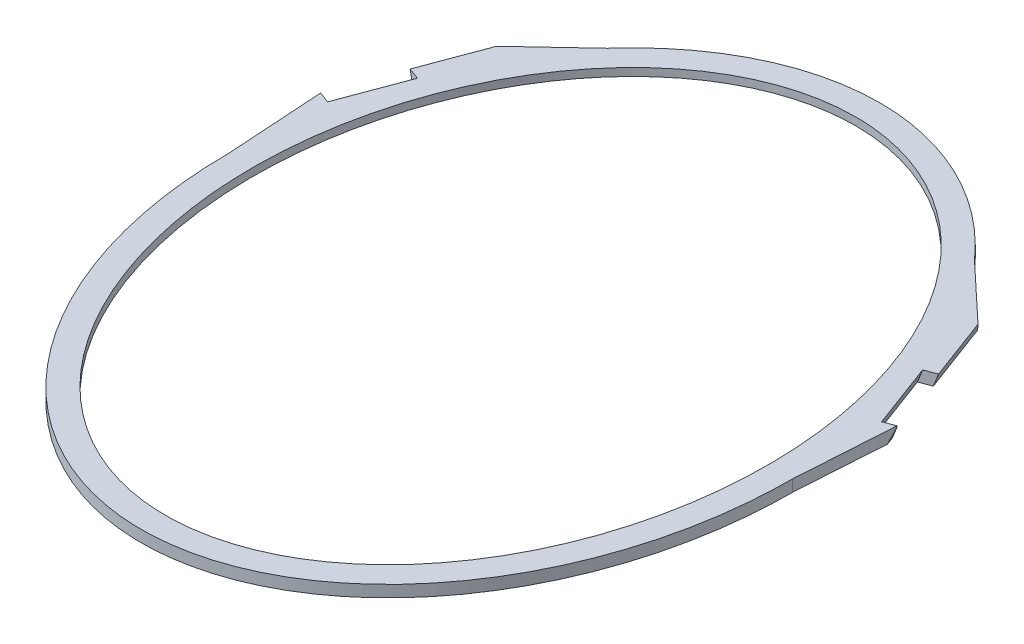
from build123d import *

# Parameters (mm, degrees)
SKETCH1_RX          = 380
SKETCH1_RY          = 290
SKETCH1_RX_2        = 355
SKETCH1_RY_2        = 265
BOSS_EXTRUDE1_DEPTH = 12
SKETCH2_RX          = 365
SKETCH2_RY          = 275
SKETCH2_RX_2        = 355
SKETCH2_RY_2        = 265
CUT_EXTRUDE1_DEPTH  = 4
BOSS_EXTRUDE2_DEPTH = 12
SKETCH5_W           = 309.529934858
SKETCH5_H           = 171.672064711
CUT_EXTRUDE2_DEPTH  = 735.328268392
CUT_EXTRUDE3_DEPTH  = 12


with BuildPart() as part:
    # Sketch1 → Boss-Extrude1 (new body)
    with BuildSketch(Plane(origin=(0, 0, 0), x_dir=(1, 0, 0), z_dir=(0, 1, 0))):
        with Locations(Location((0, 0), (0, 0, 90))):
            Ellipse(SKETCH1_RX, SKETCH1_RY)
        with Locations(Location((0, 0), (0, 0, 90))):
            Ellipse(SKETCH1_RX_2, SKETCH1_RY_2, mode=Mode.SUBTRACT)
    extrude(amount=BOSS_EXTRUDE1_DEPTH)

    # Sketch2 → Cut-Extrude1 (cut)
    with BuildSketch(Plane.XZ):
        with Locations(Location((0, 0), (0, 0, 90))):
            Ellipse(SKETCH2_RX, SKETCH2_RY)
        with Locations(Location((0, 0), (0, 0, 90))):
            Ellipse(SKETCH2_RX_2, SKETCH2_RY_2, mode=Mode.SUBTRACT)
    extrude(amount=-CUT_EXTRUDE1_DEPTH, mode=Mode.SUBTRACT)

    # Sketch4 → Boss-Extrude2 (add)
    with BuildSketch(Plane.XZ):
        Polygon((-290, 0), (-295.575664035, -86.619712155), (-301.740501189, -182.392415904), (-247.632092978, -233.180788145), (-240.893988337, -239.505449654), (-188.989530622, -288.225103524), (-243.259040828, -170.232954756), (-265.307990562, -122.294380272), align=None)
    boss_extrude2 = extrude(amount=-BOSS_EXTRUDE2_DEPTH)

    # Sketch5 → Cut-Extrude2 (cut, through all)
    with BuildSketch(Plane(origin=(-258.254517009, -96.35508405, -96.35508405), x_dir=(-0.3091654315444503, -0.11535001008591941, 0.9439868172337536), z_dir=(-0.8844332774281072, -0.32998316455372234, -0.32998316455372073))):
        with Locations((-84.653103238, 107.13606779)):
            Rectangle(SKETCH5_W, SKETCH5_H)
    cut_extrude2 = extrude(amount=CUT_EXTRUDE2_DEPTH, mode=Mode.SUBTRACT)

    # Sketch6 → Cut-Extrude3 (cut)
    with BuildSketch(Plane(origin=(-258.254517009, -96.35508405, -96.35508405), x_dir=(-0.30916543154444925, -0.11535001008591984, 0.9439868172337539), z_dir=(-0.8844332774281067, -0.3299831645537244, -0.3299831645537199))):
        with BuildLine():
            Line((-30.865090601, 131.785635233), (-7.176006525, 131.785635233))
            Line((-7.176006525, 131.785635233), (-4.584710226, 110.738229001))
            Line((-4.584710226, 110.738229001), (-2.005409483, 89.788254836))
            Line((-2.005409483, 89.788254836), (-73.29386872, 81.011424164))
            Line((-73.29386872, 81.011424164), (-76.400552283, 106.2449843))
            Line((-76.400552283, 106.2449843), (-144.944507271, 97.806049122))
            add(Edge.make_bspline(
                [(-537.868612965, -60.223865358), (-492.157096842, -6.578435532), (-422.520855321, 81.045468469), (-274.386448657, 128.55879657), (-187.039723393, 138.660281321), (-144.944507271, 97.806049122)],
                knots=[0, 0, 0, 0, 0.468078311, 0.64359283, 0.981724341, 0.981724341, 0.981724341, 0.981724341], degree=3))
            Line((-537.868612965, -60.223865358), (-636.026891233, -171.208244591))
            Line((-636.026891233, -171.208244591), (-643.517533775, -164.583271058))
            Line((-643.517533775, -164.583271058), (-635.491845337, -155.508885638))
            Line((-635.491845337, -155.508885638), (-642.982487879, -148.883912105))
            Line((-642.982487879, -148.883912105), (-651.008176316, -157.958297525))
            Line((-651.008176316, -157.958297525), (-658.498818858, -151.333323992))
            Line((-658.498818858, -151.333323992), (-650.473130421, -142.258938572))
            Line((-650.473130421, -142.258938572), (-657.963772962, -135.633965039))
            Line((-657.963772962, -135.633965039), (-427.114007888, 125.380371448))
            Line((-427.114007888, 125.380371448), (-418.125236838, 117.430403208))
            Line((-418.125236838, 117.430403208), (-401.767798679, 135.925227607))
            add(Edge.make_bspline(
                [(-289.768696146, 168.495546224), (-325.11063488, 151.482260648), (-362.499532822, 139.204958191), (-401.767798679, 135.925227607)],
                knots=[0, 0, 0, 0, 0.423035684, 0.423035684, 0.423035684, 0.423035684], degree=3))
            add(Edge.make_bspline(
                [(-283.026620179, 171.833838116), (-285.270101084, 170.706212791), (-287.518074448, 169.593894352), (-289.768696146, 168.495546224)],
                knots=[0.946107155, 0.946107155, 0.946107155, 0.946107155, 1, 1, 1, 1], degree=3))
            add(Edge.make_bspline(
                [(-220.87164928, 228.025535118), (-245.021206388, 192.954919504), (-283.026620179, 171.833838116)],
                knots=[0, 0, 0, 1, 1, 1], degree=2))
            Line((-220.87164928, 228.025535118), (-173.670200877, 233.306306737))
            add(Edge.make_bspline(
                [(-54.469215847, 127.311075643), (-131.48926087, 121.012429268), (-173.670200877, 233.306306737)],
                knots=[0, 0, 0, 1, 1, 1], degree=2))
            add(Edge.make_bspline(
                [(-30.865090601, 131.785635233), (-37.780770855, 129.025742334), (-45.684682956, 127.408675758), (-54.469215847, 127.311075643)],
                knots=[0.075372824, 0.075372824, 0.075372824, 0.075372824, 0.22551618, 0.22551618, 0.22551618, 0.22551618], degree=3, weights=[1, 0.918163719, 0.848614613, 0.79135268]))
        make_face()
    cut_extrude3 = extrude(amount=-CUT_EXTRUDE3_DEPTH, mode=Mode.SUBTRACT)

    # Mirror1: Boss-Extrude2, Cut-Extrude2, Cut-Extrude3 across plane
    add(boss_extrude2.mirror(Plane(origin=(0, 0, 0), x_dir=(0, 0, 1), z_dir=(1, 0, 0))))
    add(cut_extrude2.mirror(Plane(origin=(0, 0, 0), x_dir=(0, 0, 1), z_dir=(1, 0, 0))), mode=Mode.SUBTRACT)
    add(cut_extrude3.mirror(Plane(origin=(0, 0, 0), x_dir=(0, 0, 1), z_dir=(1, 0, 0))), mode=Mode.SUBTRACT)


solid = part.part
